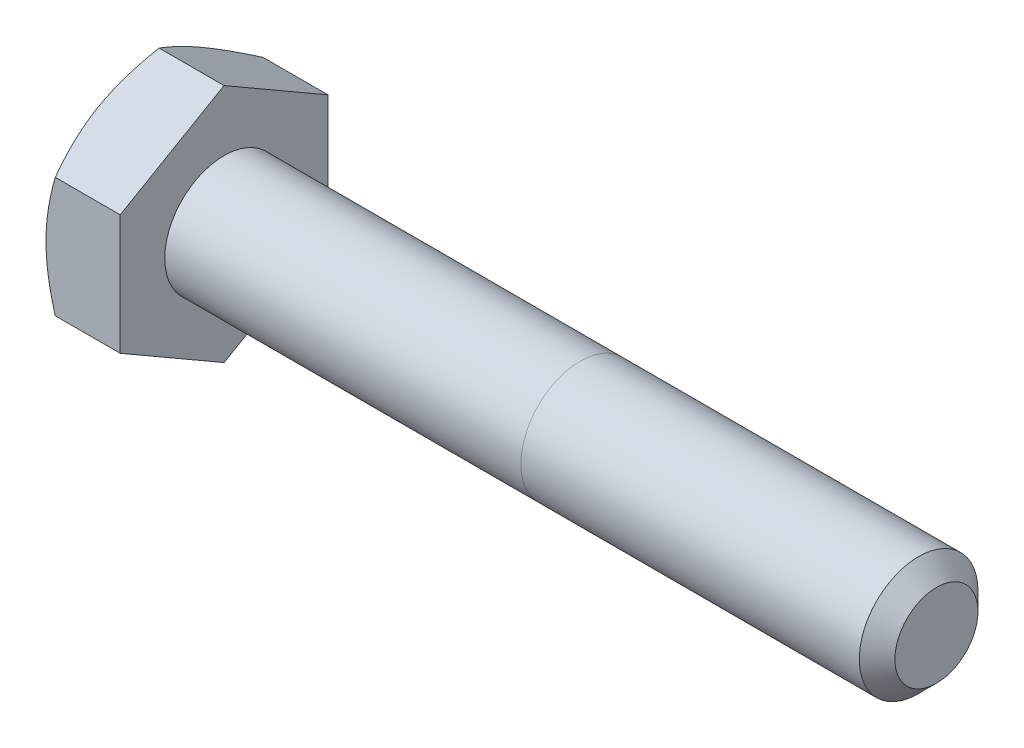
from build123d import *

# Parameters (mm, degrees)
SKETCH5_R           = 3.175
BOSS_EXTRUDE3_DEPTH = 38.1
CHAMFER1_SIZE       = 0.9525
BOSS_EXTRUDE4_DEPTH = 3.96875
SKETCH8_OUTSIDE_W   = 171.38
SKETCH8_OUTSIDE_H   = 173.1
SKETCH8_OUTSIDE_R   = 5.55625
CUT_EXTRUDE3_DEPTH  = 43.06875
CUT_EXTRUDE3_TAPER  = 60
CUT_EXTRUDE4_DEPTH  = 0.254
CIRPATTERN1_COUNT   = 3


with BuildPart() as part:
    # Sketch5 → Boss-Extrude3 (new body)
    with BuildSketch(Plane(origin=(21.034375, 0, 0), x_dir=(0, 0, -1), z_dir=(1, 0, 0))):
        Circle(SKETCH5_R)
    extrude(amount=-BOSS_EXTRUDE3_DEPTH)

    # Chamfer1
    chamfer1_edges = [part.edges().sort_by_distance(p)[0] for p in [
        (21.034375, 0, 3.175),
    ]]
    chamfer(chamfer1_edges, length=CHAMFER1_SIZE)

    # Sketch11 → Revolve1 (revolve)
    with BuildSketch(Plane.XY):
        Polygon((-17.065625, 3.175), (-17.065625, 0), (5.159375, 0), (1.984375, 3.175), align=None)
    revolve(axis=Axis((-17.065625, 0, 0), (1, 0, 0)))

    # Sketch6 → Boss-Extrude4 (add)
    with BuildSketch(Plane.ZY.offset(17.065625)):
        Polygon((5.55625, 3.207902433), (0, 6.415804866), (-5.55625, 3.207902433), (-5.55625, -3.207902433), (0, -6.415804866), (5.55625, -3.207902433), align=None)
    extrude(amount=BOSS_EXTRUDE4_DEPTH)

    # Sketch8 outside → Cut-Extrude3 (cut, through all)
    with BuildSketch(Plane.ZY.offset(21.034375)):
        Rectangle(SKETCH8_OUTSIDE_W, SKETCH8_OUTSIDE_H)
        Circle(SKETCH8_OUTSIDE_R, mode=Mode.SUBTRACT)
    extrude(amount=-CUT_EXTRUDE3_DEPTH, taper=CUT_EXTRUDE3_TAPER, mode=Mode.SUBTRACT)

    # Sketch12 → Cut-Extrude4 (cut)
    with BuildSketch(Plane.ZY.offset(21.034375)):
        with BuildLine():
            Line((0.1666875, 4.2783125), (0.1666875, 2.3891875))
            ThreePointArc((0.1666875, 2.3891875), (0, 2.2225), (-0.1666875, 2.3891875))
            Line((-0.1666875, 2.3891875), (-0.1666875, 4.2783125))
            ThreePointArc((-0.1666875, 4.2783125), (0, 4.445), (0.1666875, 4.2783125))
        make_face()
    cut_extrude4 = extrude(amount=-CUT_EXTRUDE4_DEPTH, mode=Mode.SUBTRACT)

    # CirPattern1: Cut-Extrude4 ×3 about axis
    cirpattern1_axis = Axis((0, 0, 0), (1, 0, 0))
    for i in range(1, CIRPATTERN1_COUNT):
        add(cut_extrude4.rotate(cirpattern1_axis, i * 360 / CIRPATTERN1_COUNT), mode=Mode.SUBTRACT)


solid = part.part
